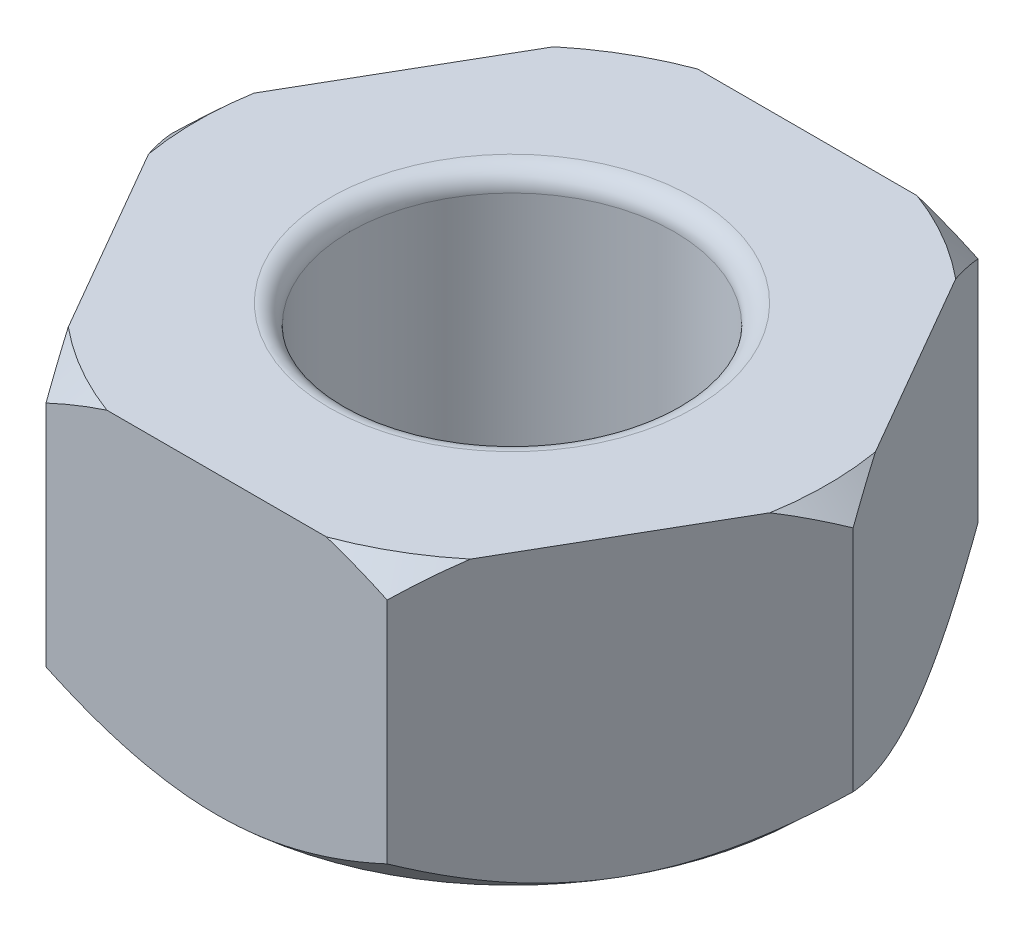
from build123d import *

# Parameters (mm, degrees)
SALIENTE_EXTRUIR1_DEPTH = 15
CROQUIS2_OUTSIDE_W      = 78.456
CROQUIS2_OUTSIDE_H      = 73.814
CROQUIS2_OUTSIDE_R      = 16
CORTAR_EXTRUIR1_DEPTH   = 15
CORTAR_EXTRUIR1_TAPER   = 47
CROQUIS3_OUTSIDE_W      = 78.456
CROQUIS3_OUTSIDE_H      = 73.814
CROQUIS3_OUTSIDE_R      = 15
CORTAR_EXTRUIR2_DEPTH   = 15
CORTAR_EXTRUIR2_TAPER   = 47
CROQUIS4_R              = 8.25
CORTAR_EXTRUIR3_DEPTH   = 15
REDONDEO1_R             = 1


with BuildPart() as part:
    # Croquis1 → Saliente-Extruir1 (new body)
    with BuildSketch(Plane(origin=(0, 0, 0), x_dir=(1, 0, 0), z_dir=(0, 1, 0))):
        Polygon((-8.660254038, -15), (8.660254038, -15), (17.320508076, 0), (8.660254038, 15), (-8.660254038, 15), (-17.320508076, 0), align=None)
    extrude(amount=-SALIENTE_EXTRUIR1_DEPTH)

    # Croquis2 outside → Cortar-Extruir1 (cut)
    with BuildSketch(Plane(origin=(0, 0, 0), x_dir=(1, 0, 0), z_dir=(0, 1, 0))):
        Rectangle(CROQUIS2_OUTSIDE_W, CROQUIS2_OUTSIDE_H)
        Circle(CROQUIS2_OUTSIDE_R, mode=Mode.SUBTRACT)
    extrude(amount=-CORTAR_EXTRUIR1_DEPTH, taper=CORTAR_EXTRUIR1_TAPER, mode=Mode.SUBTRACT)

    # Croquis3 outside → Cortar-Extruir2 (cut)
    with BuildSketch(Plane.XZ.offset(15)):
        Rectangle(CROQUIS3_OUTSIDE_W, CROQUIS3_OUTSIDE_H)
        Circle(CROQUIS3_OUTSIDE_R, mode=Mode.SUBTRACT)
    extrude(amount=-CORTAR_EXTRUIR2_DEPTH, taper=CORTAR_EXTRUIR2_TAPER, mode=Mode.SUBTRACT)

    # Croquis4 → Cortar-Extruir3 (cut)
    with BuildSketch(Plane(origin=(0, 0, 0), x_dir=(1, 0, 0), z_dir=(0, 1, 0))):
        Circle(CROQUIS4_R)
    extrude(amount=-CORTAR_EXTRUIR3_DEPTH, mode=Mode.SUBTRACT)

    # Redondeo1
    redondeo1_edges = [part.edges().sort_by_distance(p)[0] for p in [
        (-8.25, -15, 0),
        (-8.25, 0, 0),
    ]]
    fillet(redondeo1_edges, radius=REDONDEO1_R)


solid = part.part
